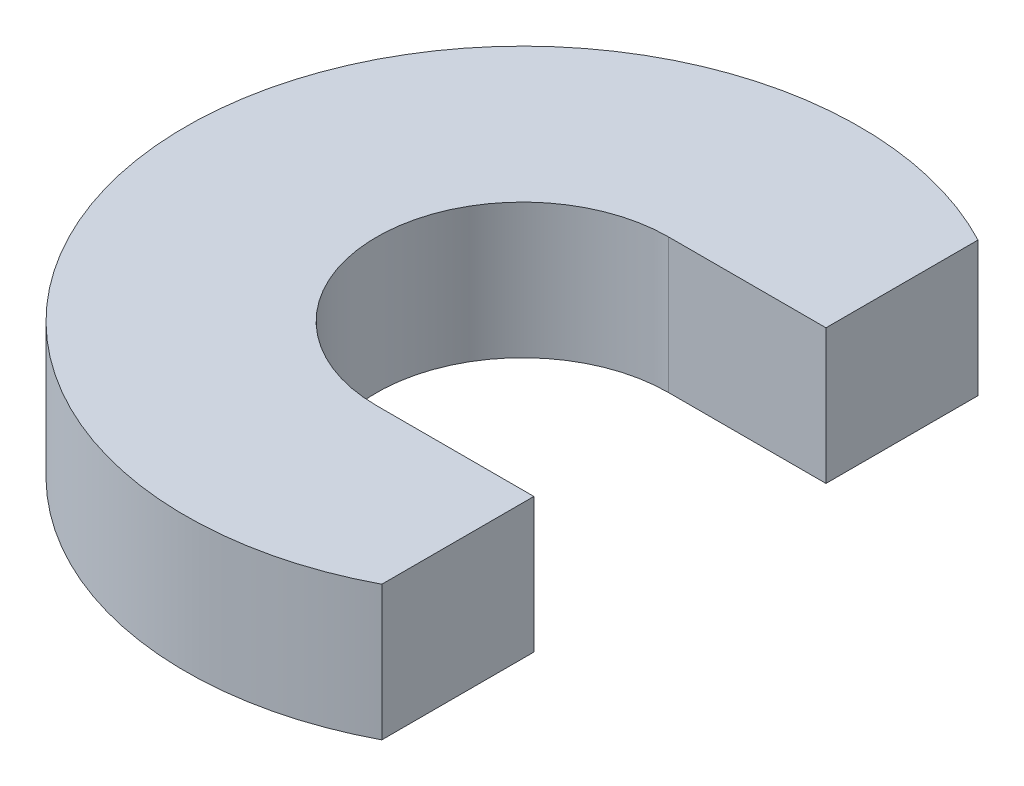
from build123d import *

# Parameters (mm, degrees)
BOSS_EXTRUDE1_DEPTH = 1.524


with BuildPart() as part:
    # Sketch1 → Boss-Extrude1 (new body)
    with BuildSketch(Plane(origin=(0, 0, 0), x_dir=(1, 0, 0), z_dir=(0, 1, 0))):
        with BuildLine():
            Line((0, 1.651), (1.778, 1.651))
            Line((1.778, 1.651), (1.778, 3.369690787))
            ThreePointArc((1.778, 3.369690787), (-3.81, 0), (1.778, -3.369690787))
            Line((1.778, -3.369690787), (1.778, -1.651))
            Line((1.778, -1.651), (0, -1.651))
            ThreePointArc((0, -1.651), (-1.651, 0), (0, 1.651))
        make_face()
    extrude(amount=BOSS_EXTRUDE1_DEPTH)


solid = part.part
